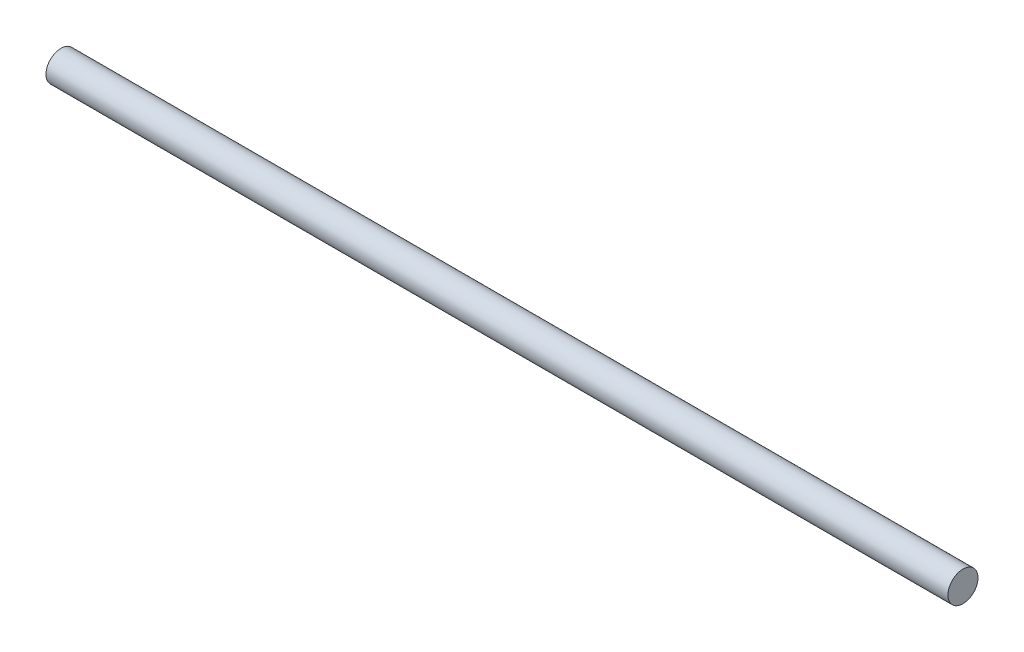
from build123d import *

# Parameters (mm, degrees)
SKETCH1_R           = 9.525
BOSS_EXTRUDE1_DEPTH = 571.5


with BuildPart() as part:
    # Sketch1 → Boss-Extrude1 (new body)
    with BuildSketch(Plane(origin=(0, 0, 0), x_dir=(0, 0, -1), z_dir=(1, 0, 0))):
        Circle(SKETCH1_R)
    extrude(amount=BOSS_EXTRUDE1_DEPTH)


solid = part.part
